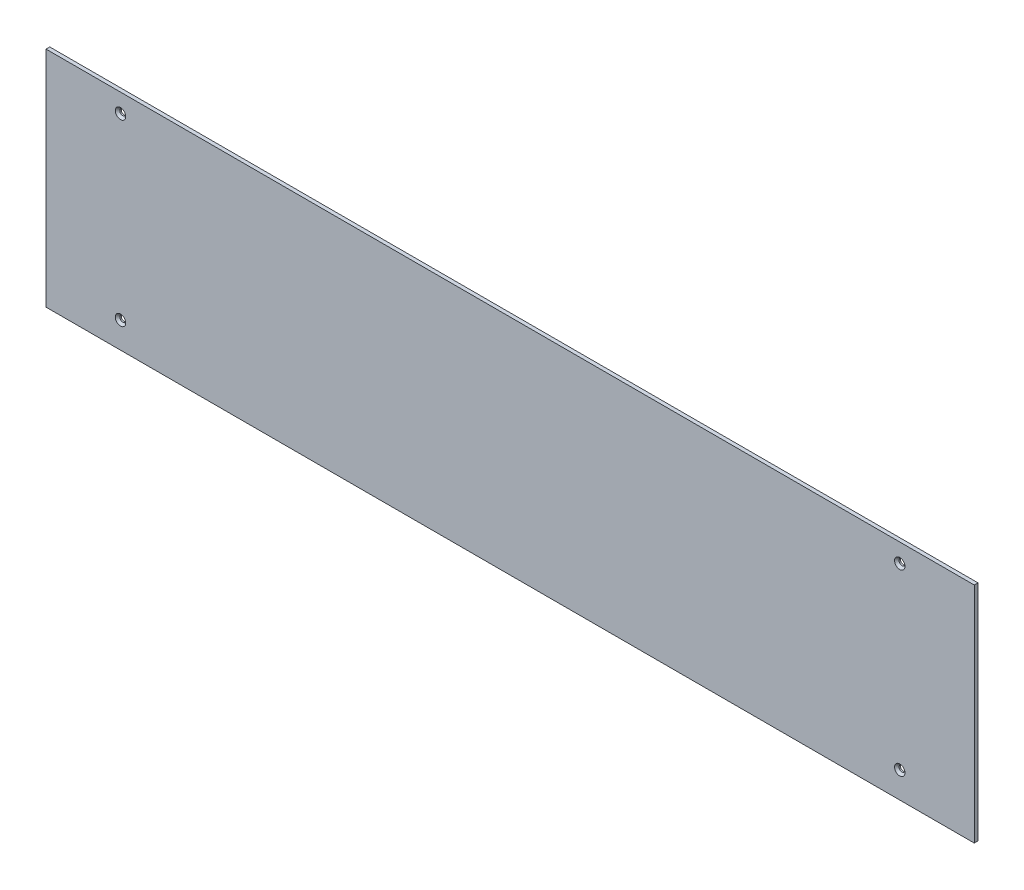
from build123d import *

# Parameters (mm, degrees)
SKETCH1_W           = 1246
SKETCH1_H           = 300
BOSS_EXTRUDE1_DEPTH = 5
SKETCH2_R           = 4
CUT_EXTRUDE1_DEPTH  = 6
CHAMFER1_SIZE       = 3


with BuildPart() as part:
    # Sketch1 → Boss-Extrude1 (new body)
    with BuildSketch(Plane.XY):
        Rectangle(SKETCH1_W, SKETCH1_H)
    extrude(amount=BOSS_EXTRUDE1_DEPTH)

    # Sketch2 → Cut-Extrude1 (cut, through all)
    with BuildSketch(Plane.XY.offset(5)):
        with Locations((-523, 125)):
            Circle(SKETCH2_R)
        with Locations((523, 125)):
            Circle(SKETCH2_R)
        with Locations((523, -115)):
            Circle(SKETCH2_R)
        with Locations((-523, -115)):
            Circle(SKETCH2_R)
    extrude(amount=-CUT_EXTRUDE1_DEPTH, mode=Mode.SUBTRACT)

    # Chamfer1
    chamfer1_edges = [part.edges().sort_by_distance(p)[0] for p in [
        (-527, 125, 5),
        (519, 125, 5),
        (519, -115, 5),
        (-527, -115, 5),
    ]]
    chamfer(chamfer1_edges, length=CHAMFER1_SIZE)


solid = part.part
